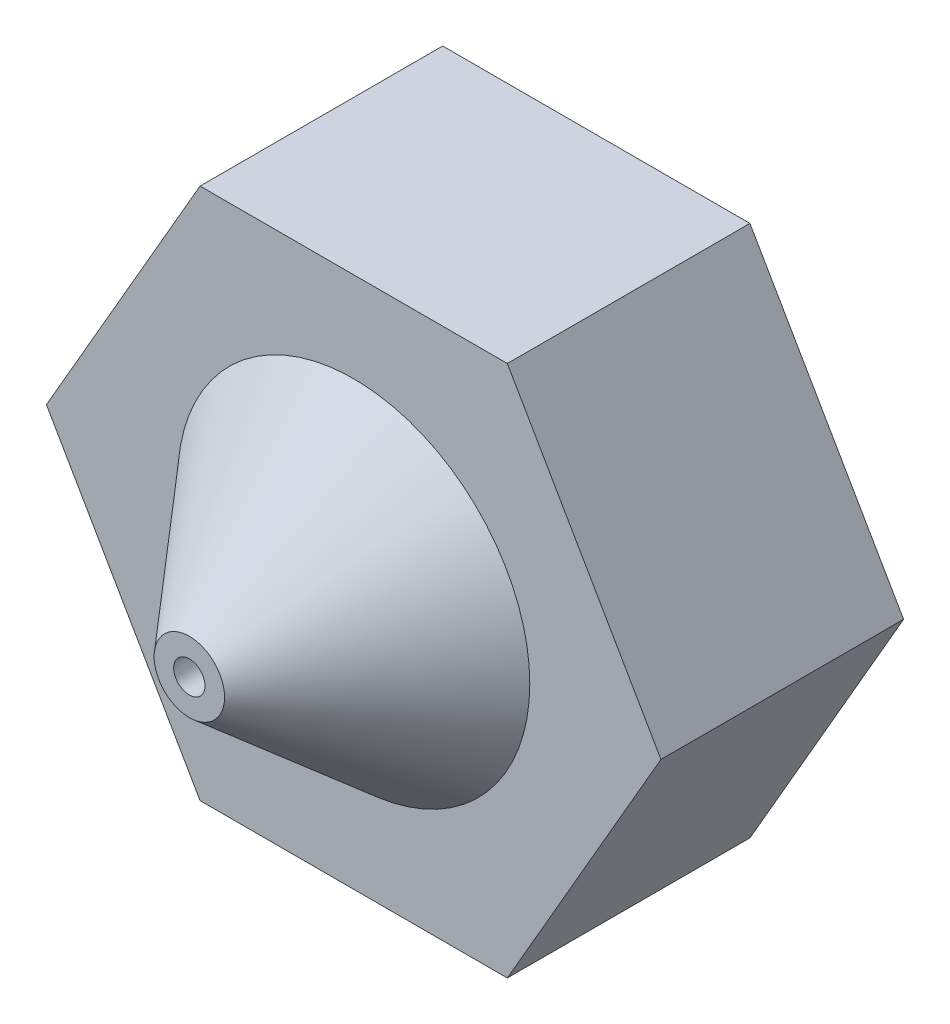
from build123d import *

# Parameters (mm, degrees)
RESSALTO_EXTRUS_O1_DEPTH = 3.1
ESBO_O3_R                = 2.25
ESBO_O2_R                = 0.45
ESBO_O4_R                = 0.2
CORTE_EXTRUS_O1_DEPTH    = 6.2


with BuildPart() as part:
    # Esboço1 → Ressalto-extrusão1 (new body)
    with BuildSketch(Plane.XY):
        Polygon((-3.637009085, 1.6), (-1.67401817, 5), (-3.637009085, 8.4), (-7.562990915, 8.4), (-9.52598183, 5), (-7.562990915, 1.6), align=None)
    extrude(amount=RESSALTO_EXTRUS_O1_DEPTH)

    # Esboço3 → Loft3 section 0
    with BuildSketch(Plane.XY.offset(3.1)):
        with Locations((-5.6, 5)):
            Circle(ESBO_O3_R)
    # Esboço2 → Loft3 section 1
    with BuildSketch(Plane.XY.offset(5.2)):
        with Locations((-5.6, 5)):
            Circle(ESBO_O2_R)
    loft()

    # Esboço4 → Corte-extrusão1 (cut, through all)
    with BuildSketch(Plane.XY.offset(5.2)):
        with Locations((-5.6, 5)):
            Circle(ESBO_O4_R)
    extrude(amount=-CORTE_EXTRUS_O1_DEPTH, mode=Mode.SUBTRACT)


solid = part.part
